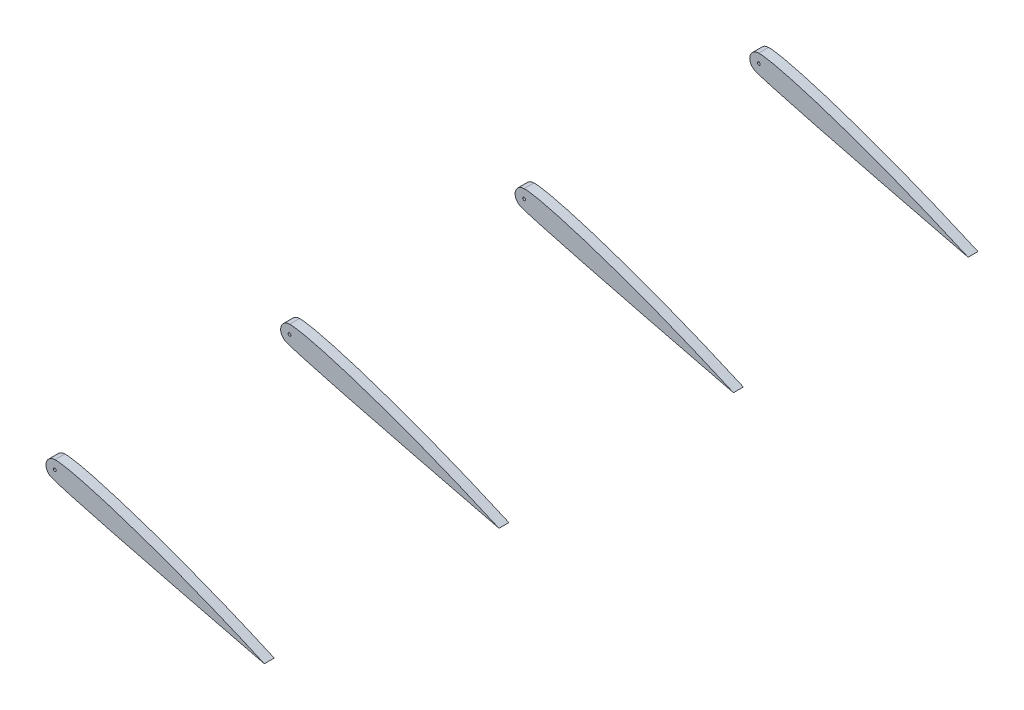
from build123d import *

# Parameters (mm, degrees)
BOSS_EXTRUDE1_DEPTH = 2.999994
BOSS_EXTRUDE2_DEPTH = 2.999994
BOSS_EXTRUDE3_DEPTH = 2.999994
BOSS_EXTRUDE4_DEPTH = 2.999994
SKETCH6_R           = 0.432278284
CUT_EXTRUDE1_DEPTH  = 217.3599941


with BuildPart() as part:
    # Sketch1 → Boss-Extrude1 (new body)
    with BuildSketch(Plane.XY):
        with BuildLine():
            ThreePointArc((-30.404523451, 10.809351549), (-32.988123249, 8.866669081), (-31.839100998, 5.84528679))
            add(Edge.make_bspline(
                [(-31.839100998, 5.84528679), (-29.631865324, 4.267485569), (33.093846915, -11.018339962)],
                knots=[0, 0, 0, 1, 1, 1], degree=2))
            add(Edge.make_bspline(
                [(-30.404523451, 10.809351549), (-26.119973685, 11.227328374), (0.623008073, 3.417982016), (33.093846915, -11.018339962)],
                knots=[0, 0, 0, 0, 1, 1, 1, 1], degree=3))
        make_face()
    extrude(amount=BOSS_EXTRUDE1_DEPTH)


with BuildPart() as body_2:
    # Sketch3 → Boss-Extrude2 (new body)
    with BuildSketch(Plane.XY.offset(-71.12)):
        with BuildLine():
            ThreePointArc((-30.404523451, 10.809351549), (-32.988123249, 8.866669081), (-31.839100998, 5.84528679))
            add(Edge.make_bspline(
                [(-31.839100998, 5.84528679), (-29.631865324, 4.267485569), (33.093846915, -11.018339962)],
                knots=[0, 0, 0, 1, 1, 1], degree=2))
            add(Edge.make_bspline(
                [(-30.404523451, 10.809351549), (-26.119973685, 11.227328374), (0.623008073, 3.417982016), (33.093846915, -11.018339962)],
                knots=[0, 0, 0, 0, 1, 1, 1, 1], degree=3))
        make_face()
    extrude(amount=BOSS_EXTRUDE2_DEPTH)


with BuildPart() as body_3:
    # Sketch4 → Boss-Extrude3 (new body)
    with BuildSketch(Plane.XY.offset(-142.24)):
        with BuildLine():
            ThreePointArc((-30.460508952, 10.811771501), (-33.04410875, 8.869089034), (-31.895086499, 5.847706742))
            add(Edge.make_bspline(
                [(-31.895086499, 5.847706742), (-29.687850825, 4.269905522), (33.037861414, -11.015920009)],
                knots=[0, 0, 0, 1, 1, 1], degree=2))
            add(Edge.make_bspline(
                [(-30.460508952, 10.811771501), (-26.175959186, 11.229748327), (0.567022572, 3.420401969), (33.037861414, -11.015920009)],
                knots=[0, 0, 0, 0, 1, 1, 1, 1], degree=3))
        make_face()
    extrude(amount=BOSS_EXTRUDE3_DEPTH)


with BuildPart() as body_4:
    # Sketch5 → Boss-Extrude4 (new body)
    with BuildSketch(Plane.XY.offset(-213.36)):
        with BuildLine():
            ThreePointArc((-30.460508952, 10.811771501), (-33.04410875, 8.869089034), (-31.895086499, 5.847706742))
            add(Edge.make_bspline(
                [(-31.895086499, 5.847706742), (-29.687850825, 4.269905522), (33.037861414, -11.015920009)],
                knots=[0, 0, 0, 1, 1, 1], degree=2))
            add(Edge.make_bspline(
                [(-30.460508952, 10.811771501), (-26.175959186, 11.229748327), (0.567022572, 3.420401969), (33.037861414, -11.015920009)],
                knots=[0, 0, 0, 0, 1, 1, 1, 1], degree=3))
        make_face()
    extrude(amount=BOSS_EXTRUDE4_DEPTH)


with BuildPart() as cut_extrude1_tool:
    # Sketch6 → Cut-Extrude1 (new body, through all)
    with BuildSketch(Plane.XY.offset(2.999994)):
        with Locations((-30.404523451, 8.120028084)):
            Circle(SKETCH6_R)
    extrude(amount=-CUT_EXTRUDE1_DEPTH)


with BuildPart() as part_1:
    add(part.part)

    # Cut-Extrude1: cut by cut_extrude1_tool
    add(cut_extrude1_tool.part, mode=Mode.SUBTRACT)


with BuildPart() as body_2_1:
    add(body_2.part)

    # Cut-Extrude1: cut by cut_extrude1_tool
    add(cut_extrude1_tool.part, mode=Mode.SUBTRACT)


with BuildPart() as body_3_1:
    add(body_3.part)

    # Cut-Extrude1: cut by cut_extrude1_tool
    add(cut_extrude1_tool.part, mode=Mode.SUBTRACT)


with BuildPart() as body_4_1:
    add(body_4.part)

    # Cut-Extrude1: cut by cut_extrude1_tool
    add(cut_extrude1_tool.part, mode=Mode.SUBTRACT)


solid = Compound([part_1.part, body_2_1.part, body_3_1.part, body_4_1.part])
